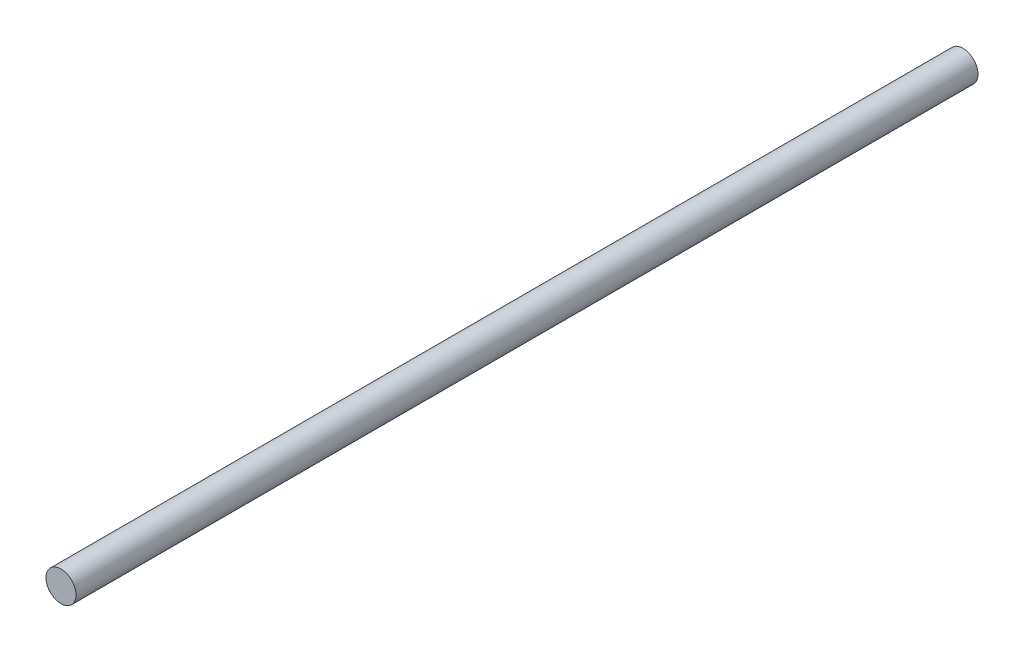
from build123d import *

# Parameters (mm, degrees)
SKETCH1_R           = 0.3
BOSS_EXTRUDE1_DEPTH = 18


with BuildPart() as part:
    # Sketch1 → Boss-Extrude1 (new body)
    with BuildSketch(Plane.XY):
        Circle(SKETCH1_R)
    extrude(amount=BOSS_EXTRUDE1_DEPTH)


solid = part.part
